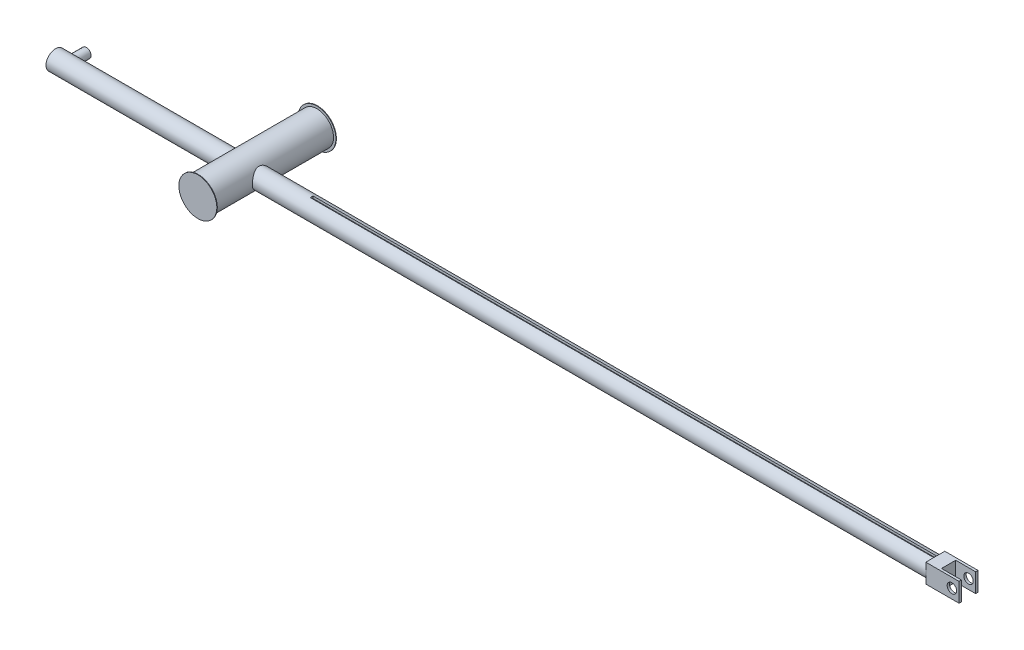
from build123d import *

# Parameters (mm, degrees)
SKETCH_1_R           = 2
EXTRUDE_1_DEPTH      = 192.4
SKETCH_2_R           = 1
EXTRUDE_2_DEPTH      = 4.5
SKETCH_3_R           = 3.5
EXTRUDE_3_DEPTH      = 10
EXTRUDE_3_DEPTH_BACK = 15.1
SKETCH_4_R           = 4
EXTRUDE_4_DEPTH      = 0.1
SKETCH_5_R           = 4
EXTRUDE_5_DEPTH      = 0.1
SKETCH_6_W           = 7
SKETCH_6_H           = 4
EXTRUDE_6_DEPTH      = 2
SKETCH_7_W           = 4.2
SKETCH_7_H           = 3
CUT_EXTRUDE_1_DEPTH  = 2
SKETCH_8_R           = 1
CUT_EXTRUDE_2_DEPTH  = 2
SKETCH_9_W           = 131.4
SKETCH_9_H           = 0.6
CUT_EXTRUDE_3_DEPTH  = 0.5


with BuildPart() as part:
    # 草图1 → 凸台-拉伸1 (new body)
    with BuildSketch(Plane(origin=(0, 0, 0), x_dir=(0, 0, -1), z_dir=(1, 0, 0))):
        Circle(SKETCH_1_R)
    extrude(amount=EXTRUDE_1_DEPTH)

    # 草图2 → 凸台-拉伸2 (add)
    with BuildSketch(Plane.XY):
        with Locations((2, 0)):
            Circle(SKETCH_2_R)
    extrude(amount=-EXTRUDE_2_DEPTH)

    # 草图3 → 凸台-拉伸3 (add, two sides)
    with BuildSketch(Plane.XY) as extrude_3_sk:
        with Locations((40, 0)):
            Circle(SKETCH_3_R)
    extrude(amount=EXTRUDE_3_DEPTH)
    extrude(extrude_3_sk.sketch, amount=-EXTRUDE_3_DEPTH_BACK)

    # 草图4 → 凸台-拉伸4 (add)
    with BuildSketch(Plane.XY.offset(10)):
        with Locations((40, 0)):
            Circle(SKETCH_4_R)
    extrude(amount=-EXTRUDE_4_DEPTH)

    # 草图5 → 凸台-拉伸5 (add)
    with BuildSketch(Plane(origin=(0, 0, -15.1), x_dir=(-1, 0, 0), z_dir=(0, 0, -1))):
        with Locations((-40, 0)):
            Circle(SKETCH_5_R)
    extrude(amount=EXTRUDE_5_DEPTH)

    # 草图6 → 凸台-拉伸6 (add, symmetric)
    with BuildSketch(Plane(origin=(0, 0, 0), x_dir=(1, 0, 0), z_dir=(0, 1, 0))):
        with Locations((188.9, 0)):
            Rectangle(SKETCH_6_W, SKETCH_6_H)
    extrude(amount=EXTRUDE_6_DEPTH, both=True)

    # 草图7 → 切除-拉伸1 (cut, symmetric)
    with BuildSketch(Plane(origin=(0, 0, 0), x_dir=(1, 0, 0), z_dir=(0, 1, 0))):
        with Locations((190.3, 0)):
            Rectangle(SKETCH_7_W, SKETCH_7_H)
    extrude(amount=CUT_EXTRUDE_1_DEPTH, both=True, mode=Mode.SUBTRACT)

    # 草图8 → 切除-拉伸2 (cut, symmetric)
    with BuildSketch(Plane.XY):
        with Locations((190.9, 0)):
            Circle(SKETCH_8_R)
    extrude(amount=CUT_EXTRUDE_2_DEPTH, both=True, mode=Mode.SUBTRACT)

    # 草图9 → 切除-拉伸3 (cut)
    with BuildSketch(Plane(origin=(0, 2, 0), x_dir=(1, 0, 0), z_dir=(0, 1, 0))):
        with Locations((119.7, 0)):
            Rectangle(SKETCH_9_W, SKETCH_9_H)
    extrude(amount=-CUT_EXTRUDE_3_DEPTH, mode=Mode.SUBTRACT)


solid = part.part
